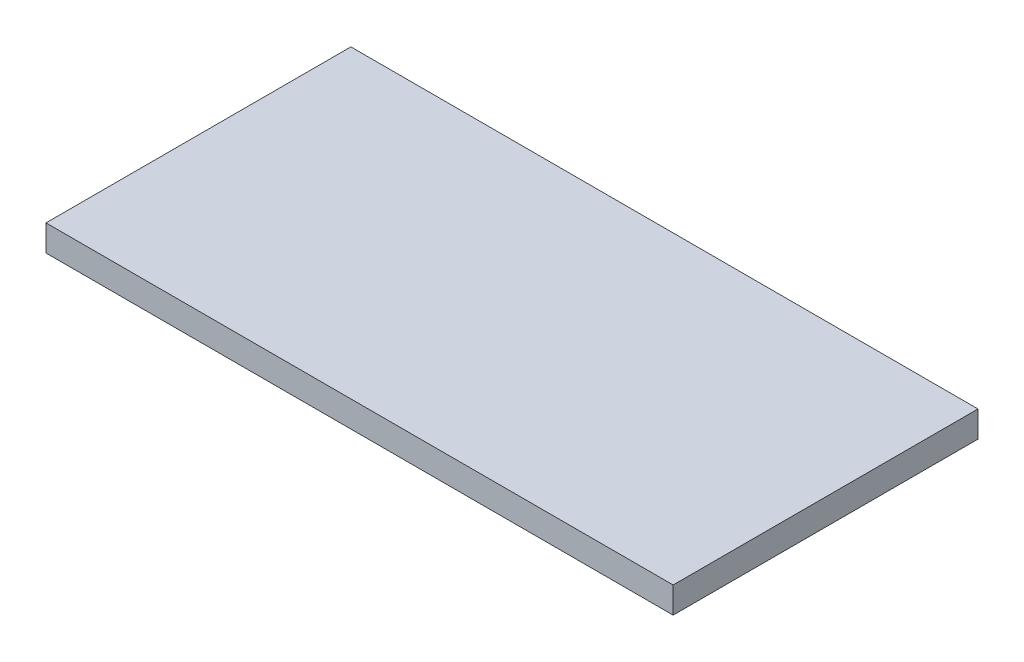
from build123d import *

# Parameters (mm, degrees)
SKETCH_1_W      = 720
SKETCH_1_H      = 350
EXTRUDE_1_DEPTH = 30


with BuildPart() as part:
    # Эскиз1 → Бобышка-Вытянуть1 (new body)
    with BuildSketch(Plane(origin=(0, 0, 0), x_dir=(1, 0, 0), z_dir=(0, 1, 0))):
        with Locations((360, 175)):
            Rectangle(SKETCH_1_W, SKETCH_1_H)
    extrude(amount=EXTRUDE_1_DEPTH)


solid = part.part
